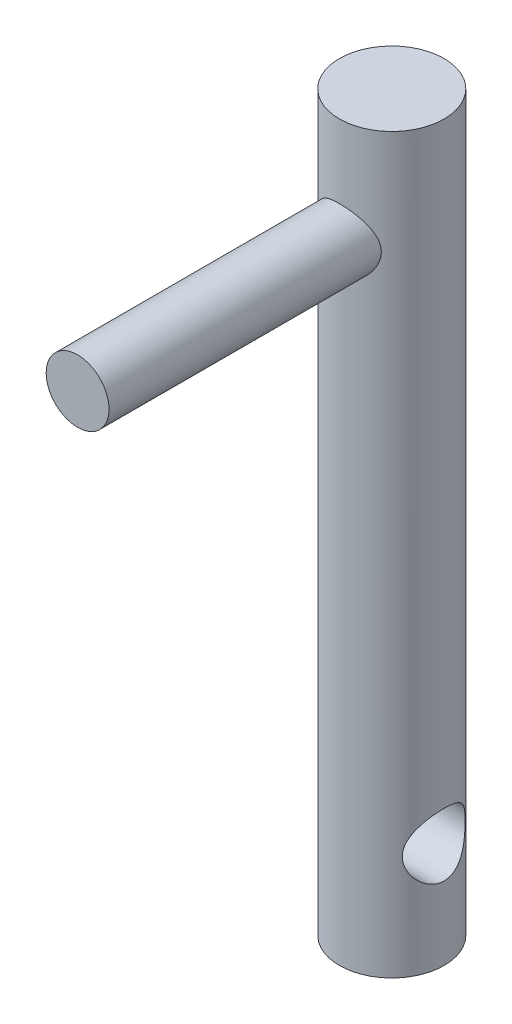
from build123d import *

# Parameters (mm, degrees)
SKETCH1_R               = 2.5
BOSS_EXTRUDE1_DEPTH     = 35
SKETCH2_R               = 1.5
CUT_EXTRUDE1_DEPTH      = 3.5
CUT_EXTRUDE1_DEPTH_BACK = 3.5
SKETCH4_R               = 1.5
BOSS_EXTRUDE3_DEPTH     = 15


with BuildPart() as part:
    # Sketch1 → Boss-Extrude1 (new body)
    with BuildSketch(Plane(origin=(0, 0, 0), x_dir=(1, 0, 0), z_dir=(0, 1, 0))):
        Circle(SKETCH1_R)
    extrude(amount=BOSS_EXTRUDE1_DEPTH)

    # Sketch2 → Cut-Extrude1 (cut, two sides)
    with BuildSketch(Plane(origin=(0, 0, 0), x_dir=(0, 0, -1), z_dir=(1, 0, 0))) as cut_extrude1_sk:
        with Locations((0, 5)):
            Circle(SKETCH2_R)
    extrude(amount=CUT_EXTRUDE1_DEPTH, mode=Mode.SUBTRACT)
    extrude(cut_extrude1_sk.sketch, amount=-CUT_EXTRUDE1_DEPTH_BACK, mode=Mode.SUBTRACT)

    # Sketch4 → Boss-Extrude3 (add)
    with BuildSketch(Plane.XY):
        with Locations((0, 30)):
            Circle(SKETCH4_R)
    extrude(amount=BOSS_EXTRUDE3_DEPTH)


solid = part.part
